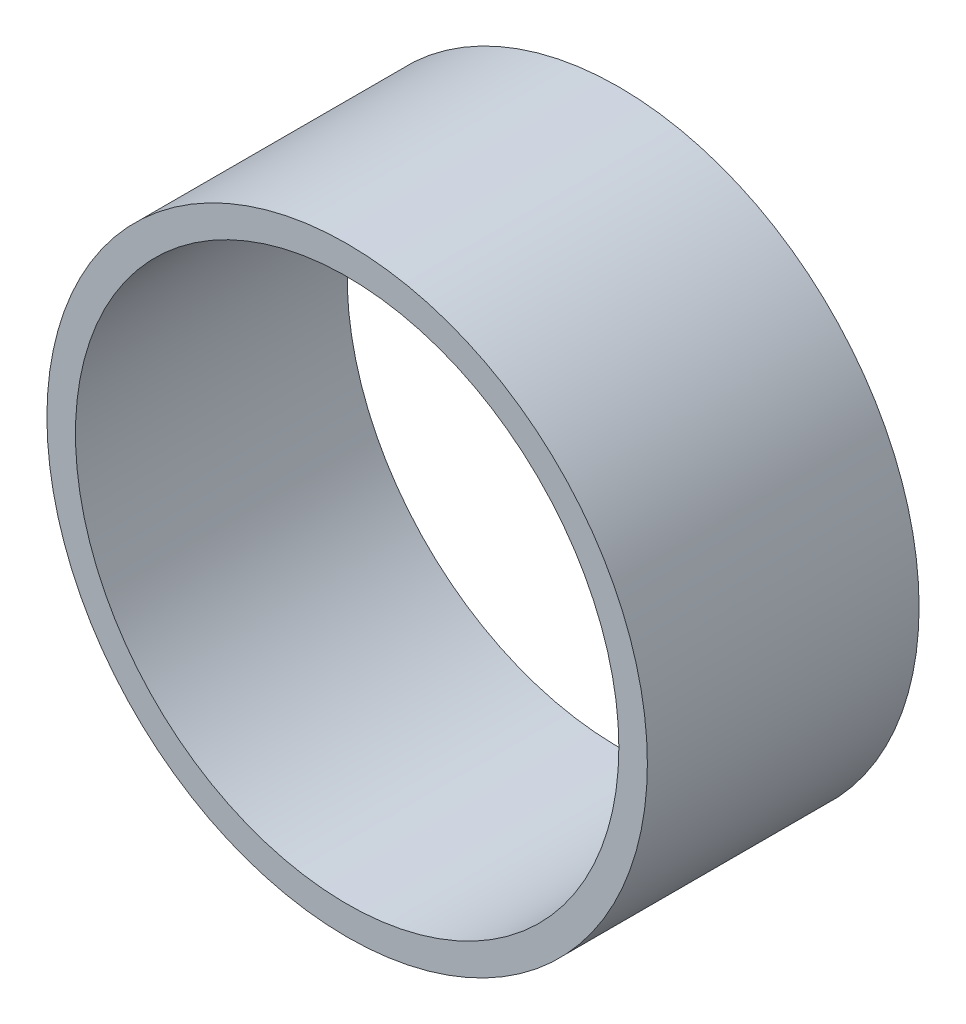
from build123d import *

# Parameters (mm, degrees)
SKETCH1_R           = 5.2625
SKETCH1_R_2         = 4.7625
BOSS_EXTRUDE1_DEPTH = 4.7625


with BuildPart() as part:
    # Sketch1 → Boss-Extrude1 (new body)
    with BuildSketch(Plane.XY):
        Circle(SKETCH1_R)
        Circle(SKETCH1_R_2, mode=Mode.SUBTRACT)
    extrude(amount=BOSS_EXTRUDE1_DEPTH)


solid = part.part
